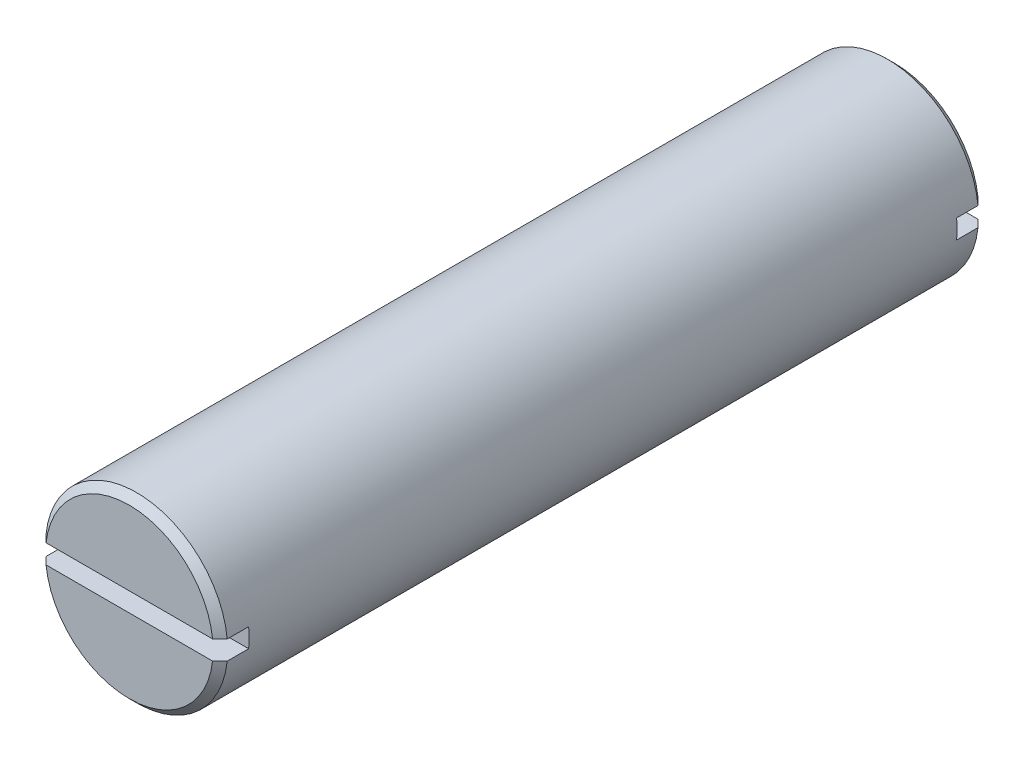
from build123d import *

# Parameters (mm, degrees)
SKETCH1_R               = 9.525
BOSS_EXTRUDE1_DEPTH     = 40
CHAMFER1_SIZE           = 0.762
SKETCH2_W               = 3
SKETCH2_H               = 2
CUT_EXTRUDE1_DEPTH      = 10.525
CUT_EXTRUDE1_DEPTH_BACK = 10.525


with BuildPart() as part:
    # Sketch1 → Boss-Extrude1 (new body, symmetric)
    with BuildSketch(Plane.XY):
        Circle(SKETCH1_R)
    extrude(amount=BOSS_EXTRUDE1_DEPTH, both=True)

    # Chamfer1
    chamfer1_edges = [part.edges().sort_by_distance(p)[0] for p in [
        (-9.525, 0, -40),
        (-9.525, 0, 40),
    ]]
    chamfer(chamfer1_edges, length=CHAMFER1_SIZE)

    # Sketch2 → Cut-Extrude1 (cut, two sides)
    with BuildSketch(Plane(origin=(0, 0, 0), x_dir=(0, 0, -1), z_dir=(1, 0, 0))) as cut_extrude1_sk:
        with Locations((-38.5, 0)):
            Rectangle(SKETCH2_W, SKETCH2_H)
        with Locations((38.5, 0)):
            Rectangle(SKETCH2_W, SKETCH2_H)
    extrude(amount=CUT_EXTRUDE1_DEPTH, mode=Mode.SUBTRACT)
    extrude(cut_extrude1_sk.sketch, amount=-CUT_EXTRUDE1_DEPTH_BACK, mode=Mode.SUBTRACT)


solid = part.part
